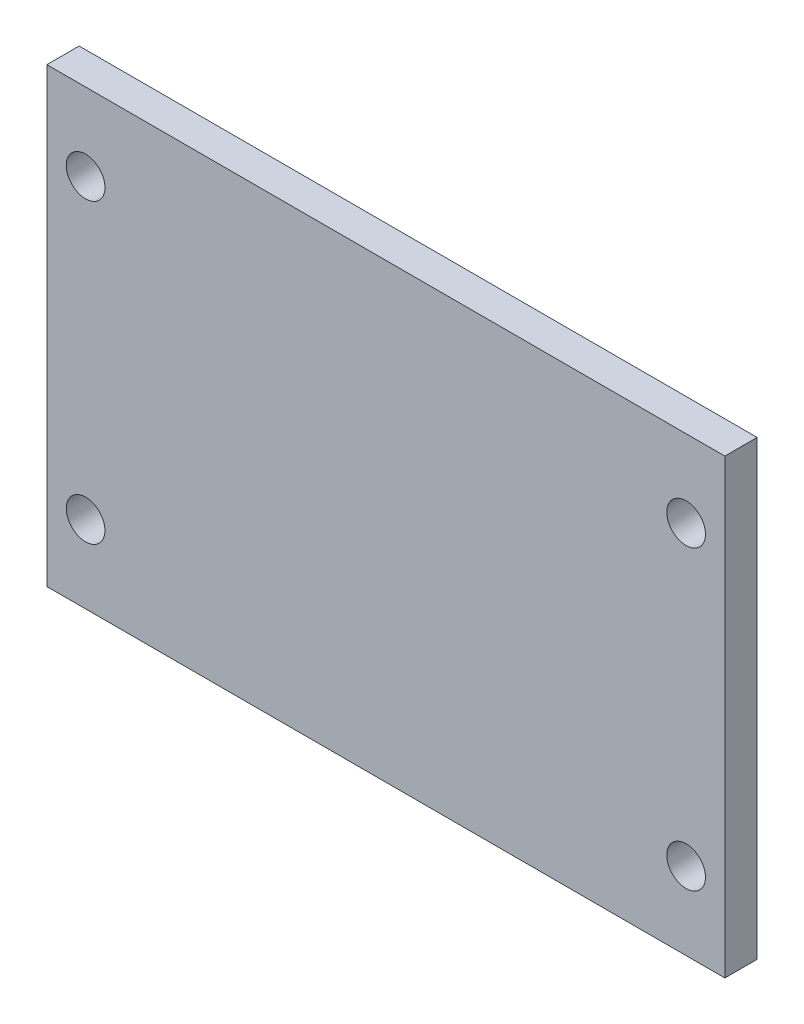
from build123d import *

# Parameters (mm, degrees)
SKETCH1_W             = 105
SKETCH1_H             = 70
BOSS_EXTRUDE1_DEPTH   = 2.5
F_6_0MM_DOWEL_HOLE1_D = 6


with BuildPart() as part:
    # Sketch1 → Boss-Extrude1 (new body, symmetric)
    with BuildSketch(Plane.XY):
        Rectangle(SKETCH1_W, SKETCH1_H)
    extrude(amount=BOSS_EXTRUDE1_DEPTH, both=True)

    # Ø6.0mm Dowel Hole1 (through all)
    with Locations(Plane.XY.offset(2.5)):
        with Locations((-46.5, 23), (-46.5, -23), (46.5, -23), (46.5, 23)):
            Hole(F_6_0MM_DOWEL_HOLE1_D / 2)


solid = part.part
